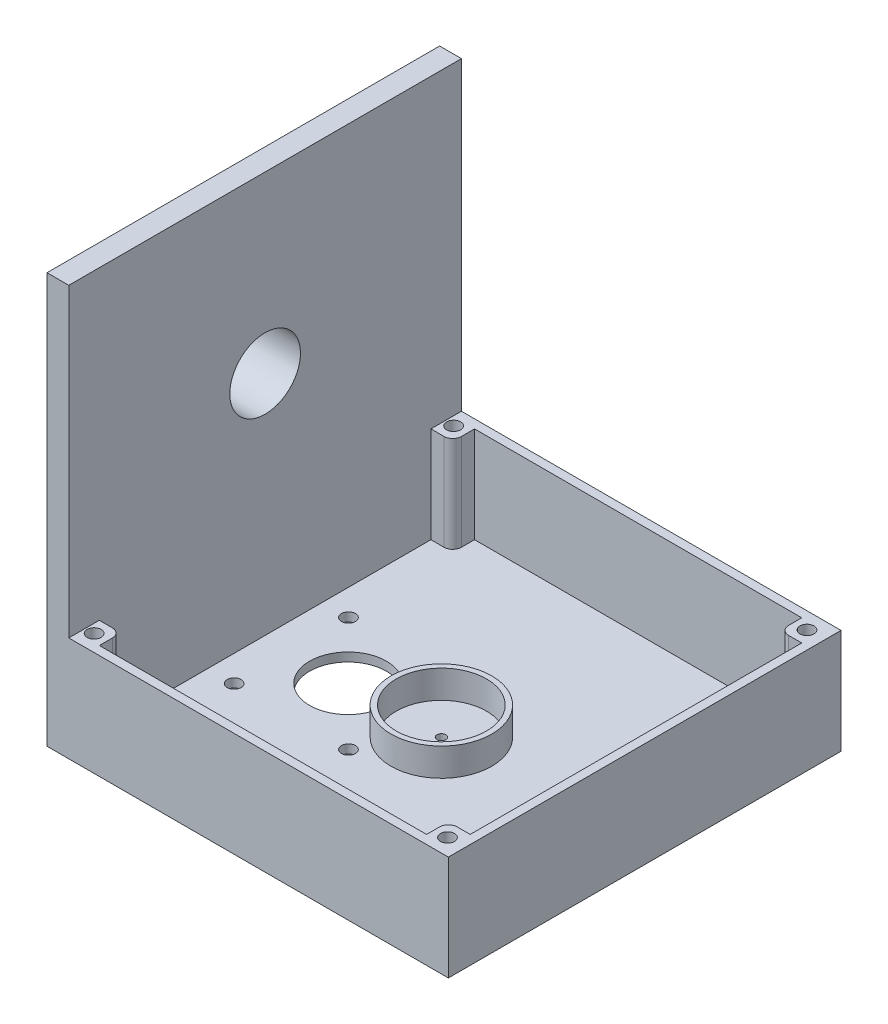
from build123d import *

# Parameters (mm, degrees)
BOSS_EXTRUDE1_DEPTH  = 114.3
SKETCH3_W            = 107.95
SKETCH3_H            = 109.22
CUT_EXTRUDE1_DEPTH   = 27.94
BOSS_EXTRUDE14_REACH = 32.48
SKETCH4_R            = 2.032
SKETCH5_R            = 2.032
SKETCH5_R_2          = 11.176
SKETCH5_R_3          = 1.27
CUT_EXTRUDE2_DEPTH   = 2.54
SKETCH7_R            = 12.319
BOSS_EXTRUDE15_DEPTH = 24.5
CUT_EXTRUDE3_REACH   = 143.34
SKETCH8_R            = 10.287
BOSS_EXTRUDE17_DEPTH = 5.08
SKETCH16_R           = 14.6685
SKETCH16_R_2         = 13.1445
BOSS_EXTRUDE18_DEPTH = 8.128


with BuildPart() as part:
    # Sketch1 → Boss-Extrude1 (new body)
    with BuildSketch(Plane.XY):
        Polygon((0, 0), (0, 88.9), (-6.35, 88.9), (-6.35, -30.48), (110.49, -30.48), (110.49, 0), align=None)
    extrude(amount=BOSS_EXTRUDE1_DEPTH)

    # Sketch3 → Cut-Extrude1 (cut)
    with BuildSketch(Plane(origin=(0, 0, 0), x_dir=(1, 0, 0), z_dir=(0, 1, 0))):
        with Locations((53.975, -57.15)):
            Rectangle(SKETCH3_W, SKETCH3_H)
    extrude(amount=-CUT_EXTRUDE1_DEPTH, mode=Mode.SUBTRACT)

    # Sketch4 → Boss-Extrude14 (add, up to next)
    with BuildSketch(Plane(origin=(0, 0, 0), x_dir=(1, 0, 0), z_dir=(0, 1, 0)), mode=Mode.PRIVATE) as boss_extrude14_sk1:
        with BuildLine():
            Line((0, -2.54), (6.35, -2.54))
            Line((6.35, -2.54), (6.35, -6.35))
            ThreePointArc((6.35, -6.35), (5.606051224, -8.146051224), (3.81, -8.89))
            Line((3.81, -8.89), (0, -8.89))
            Line((0, -8.89), (0, -2.54))
        make_face()
        with Locations((2.54, -4.826)):
            Circle(SKETCH4_R, mode=Mode.SUBTRACT)
    boss_extrude14_tool1 = extrude(boss_extrude14_sk1.sketch, amount=-BOSS_EXTRUDE14_REACH, mode=Mode.PRIVATE) - part.part
    add(boss_extrude14_tool1.solids().sort_by_distance((3.175, 0, 2.629803))[0])
    # Sketch4 → Boss-Extrude14 (add, up to next)
    with BuildSketch(Plane(origin=(0, 0, 0), x_dir=(1, 0, 0), z_dir=(0, 1, 0)), mode=Mode.PRIVATE) as boss_extrude14_sk2:
        with BuildLine():
            Line((101.6, -2.54), (101.6, -6.35))
            ThreePointArc((101.6, -6.35), (102.343948776, -8.146051224), (104.14, -8.89))
            Line((104.14, -8.89), (107.95, -8.89))
            Line((107.95, -8.89), (107.95, -2.54))
            Line((107.95, -2.54), (101.6, -2.54))
        make_face()
        with Locations((105.41, -4.826)):
            Circle(SKETCH4_R, mode=Mode.SUBTRACT)
    boss_extrude14_tool2 = extrude(boss_extrude14_sk2.sketch, amount=-BOSS_EXTRUDE14_REACH, mode=Mode.PRIVATE) - part.part
    add(boss_extrude14_tool2.solids().sort_by_distance((101.689803, 0, 4.445))[0])
    # Sketch4 → Boss-Extrude14 (add, up to next)
    with BuildSketch(Plane(origin=(0, 0, 0), x_dir=(1, 0, 0), z_dir=(0, 1, 0)), mode=Mode.PRIVATE) as boss_extrude14_sk3:
        with BuildLine():
            Line((107.95, -111.76), (101.6, -111.76))
            Line((101.6, -111.76), (101.6, -107.95))
            ThreePointArc((101.6, -107.95), (102.343948776, -106.153948776), (104.14, -105.41))
            Line((104.14, -105.41), (107.95, -105.41))
            Line((107.95, -105.41), (107.95, -111.76))
        make_face()
        with Locations((105.41, -109.474)):
            Circle(SKETCH4_R, mode=Mode.SUBTRACT)
    boss_extrude14_tool3 = extrude(boss_extrude14_sk3.sketch, amount=-BOSS_EXTRUDE14_REACH, mode=Mode.PRIVATE) - part.part
    add(boss_extrude14_tool3.solids().sort_by_distance((104.775, 0, 111.670197))[0])
    # Sketch4 → Boss-Extrude14 (add, up to next)
    with BuildSketch(Plane(origin=(0, 0, 0), x_dir=(1, 0, 0), z_dir=(0, 1, 0)), mode=Mode.PRIVATE) as boss_extrude14_sk4:
        with BuildLine():
            Line((6.35, -111.76), (6.35, -107.95))
            ThreePointArc((6.35, -107.95), (5.606051224, -106.153948776), (3.81, -105.41))
            Line((3.81, -105.41), (0, -105.41))
            Line((0, -105.41), (0, -111.76))
            Line((0, -111.76), (6.35, -111.76))
        make_face()
        with Locations((2.54, -109.474)):
            Circle(SKETCH4_R, mode=Mode.SUBTRACT)
    boss_extrude14_tool4 = extrude(boss_extrude14_sk4.sketch, amount=-BOSS_EXTRUDE14_REACH, mode=Mode.PRIVATE) - part.part
    add(boss_extrude14_tool4.solids().sort_by_distance((6.260197, 0, 109.855))[0])

    # Sketch5 → Cut-Extrude2 (cut)
    with BuildSketch(Plane.XZ.offset(30.48)):
        with Locations((7.62, 73.787)):
            Circle(SKETCH5_R)
        with Locations((40.894, 73.787)):
            Circle(SKETCH5_R)
        with Locations((40.894, 40.513)):
            Circle(SKETCH5_R)
        with Locations((7.62, 40.513)):
            Circle(SKETCH5_R)
        with Locations((24.13, 57.15)):
            Circle(SKETCH5_R_2)
        with Locations((51.308, 57.15)):
            Circle(SKETCH5_R_3)
    extrude(amount=-CUT_EXTRUDE2_DEPTH, mode=Mode.SUBTRACT)

    # Sketch7 → Boss-Extrude15 (add)
    with BuildSketch(Plane.ZY.offset(6.35)):
        with Locations((57.15, 38.1)):
            Circle(SKETCH7_R)
    extrude(amount=BOSS_EXTRUDE15_DEPTH)

    # Sketch8 → Cut-Extrude3 (cut, up to next)
    with BuildSketch(Plane.ZY.offset(30.85), mode=Mode.PRIVATE) as cut_extrude3_sk1:
        with Locations((57.15, 38.1)):
            Circle(SKETCH8_R)
    cut_extrude3_tool1 = extrude(cut_extrude3_sk1.sketch, amount=-CUT_EXTRUDE3_REACH, mode=Mode.PRIVATE) & part.part
    add(cut_extrude3_tool1.solids().sort_by_distance((-30.85, 38.1, 57.15))[0], mode=Mode.SUBTRACT)

    # Sketch11 → Boss-Extrude17 (add)
    with BuildSketch(Plane.ZY.offset(6.35)):
        with BuildLine():
            Line((54.737, 50.180363902), (54.737, 53.307305955))
            Line((54.737, 53.307305955), (59.563, 53.307305955))
            Line((59.563, 53.307305955), (59.563, 50.180363902))
            ThreePointArc((59.563, 50.180363902), (57.15, 50.419), (54.737, 50.180363902))
        make_face()
    extrude(amount=BOSS_EXTRUDE17_DEPTH)

    # Sketch16 → Boss-Extrude18 (add)
    with BuildSketch(Plane(origin=(0, -27.94, 0), x_dir=(1, 0, 0), z_dir=(0, 1, 0))):
        with Locations((51.308, -57.15)):
            Circle(SKETCH16_R)
        with Locations((51.308, -57.15)):
            Circle(SKETCH16_R_2, mode=Mode.SUBTRACT)
    extrude(amount=BOSS_EXTRUDE18_DEPTH)


solid = part.part
